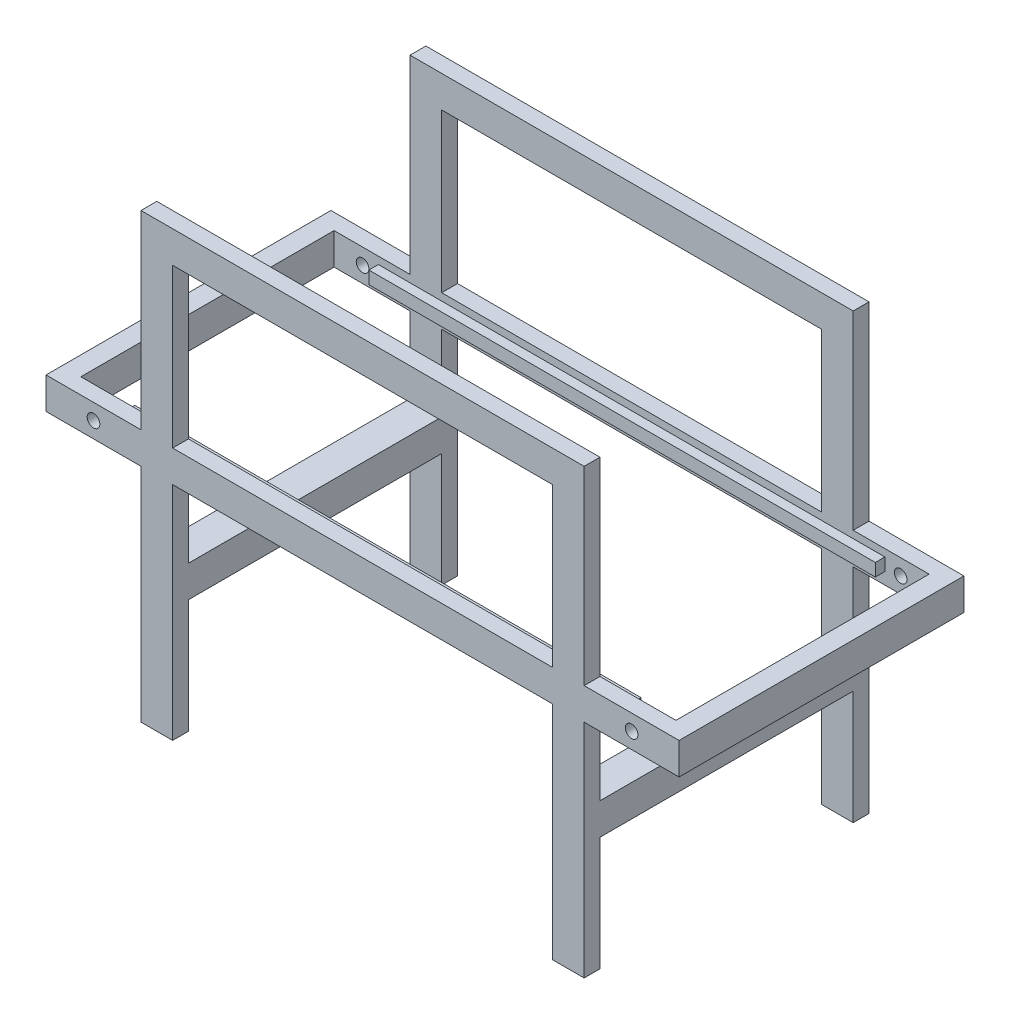
from build123d import *

# Parameters (mm, degrees)
CROQUIS1_W                   = 700
CROQUIS1_H                   = 50
CROQUIS1_W_2                 = 50
CROQUIS1_H_2                 = 250
CROQUIS1_H_3                 = 350
CROQUIS1_R                   = 10
SALIENTE_EXTRUIR1_DEPTH      = 450
CROQUIS4_W                   = 400
CROQUIS4_H                   = 470
CROQUIS4_H_2                 = 180
CORTAR_EXTRUIR1_DEPTH        = 151
CORTAR_EXTRUIR1_DEPTH_BACK   = 851
CROQUIS5_W                   = 30
CROQUIS5_H                   = 50
SALIENTE_EXTRUIR2_DEPTH      = 425
CROQUIS6_W                   = 15
CROQUIS6_H                   = 20
SALIENTE_EXTRUIR3_DEPTH      = 400
SALIENTE_EXTRUIR3_DEPTH_BACK = 400


with BuildPart() as part:
    # Croquis1 → Saliente-Extruir1 (new body)
    with BuildSketch(Plane.XY):
        with Locations((0, 325)):
            Rectangle(CROQUIS1_W, CROQUIS1_H)
        with Locations((325, 175)):
            Rectangle(CROQUIS1_W_2, CROQUIS1_H_2)
        with Locations((-325, 175)):
            Rectangle(CROQUIS1_W_2, CROQUIS1_H_2)
        with Locations((-325, -175)):
            Rectangle(CROQUIS1_W_2, CROQUIS1_H_3)
        with Locations((325, -175)):
            Rectangle(CROQUIS1_W_2, CROQUIS1_H_3)
        Polygon((-500, 50), (-500, 0), (-350, 0), (-300, 0), (300, 0), (350, 0), (500, 0), (500, 50), (350, 50), (300, 50), (-300, 50), (-350, 50), align=None)
        with Locations((-425, 25)):
            Circle(CROQUIS1_R, mode=Mode.SUBTRACT)
        with Locations((425, 25)):
            Circle(CROQUIS1_R, mode=Mode.SUBTRACT)
    extrude(amount=SALIENTE_EXTRUIR1_DEPTH)

    # Croquis4 → Cortar-Extruir1 (cut, two sides)
    with BuildSketch(Plane.ZY.offset(350)) as cortar_extruir1_sk:
        with Locations((225, 115)):
            Rectangle(CROQUIS4_W, CROQUIS4_H)
        with Locations((225, -260)):
            Rectangle(CROQUIS4_W, CROQUIS4_H_2)
    extrude(amount=CORTAR_EXTRUIR1_DEPTH, mode=Mode.SUBTRACT)
    extrude(cortar_extruir1_sk.sketch, amount=-CORTAR_EXTRUIR1_DEPTH_BACK, mode=Mode.SUBTRACT)

    # Croquis5 → Saliente-Extruir2 (add)
    with BuildSketch(Plane.XY.offset(450)):
        with Locations((-485, 25)):
            Rectangle(CROQUIS5_W, CROQUIS5_H)
        with Locations((485, 25)):
            Rectangle(CROQUIS5_W, CROQUIS5_H)
    extrude(amount=-SALIENTE_EXTRUIR2_DEPTH)

    # Croquis6 → Saliente-Extruir3 (add, two sides)
    with BuildSketch(Plane(origin=(0, 0, 0), x_dir=(0, 0, -1), z_dir=(1, 0, 0))) as saliente_extruir3_sk:
        with Locations((-32.5, 28.5)):
            Rectangle(CROQUIS6_W, CROQUIS6_H)
        with Locations((-417.5, 28.5)):
            Rectangle(CROQUIS6_W, CROQUIS6_H)
    extrude(amount=SALIENTE_EXTRUIR3_DEPTH)
    extrude(saliente_extruir3_sk.sketch, amount=-SALIENTE_EXTRUIR3_DEPTH_BACK)


solid = part.part
